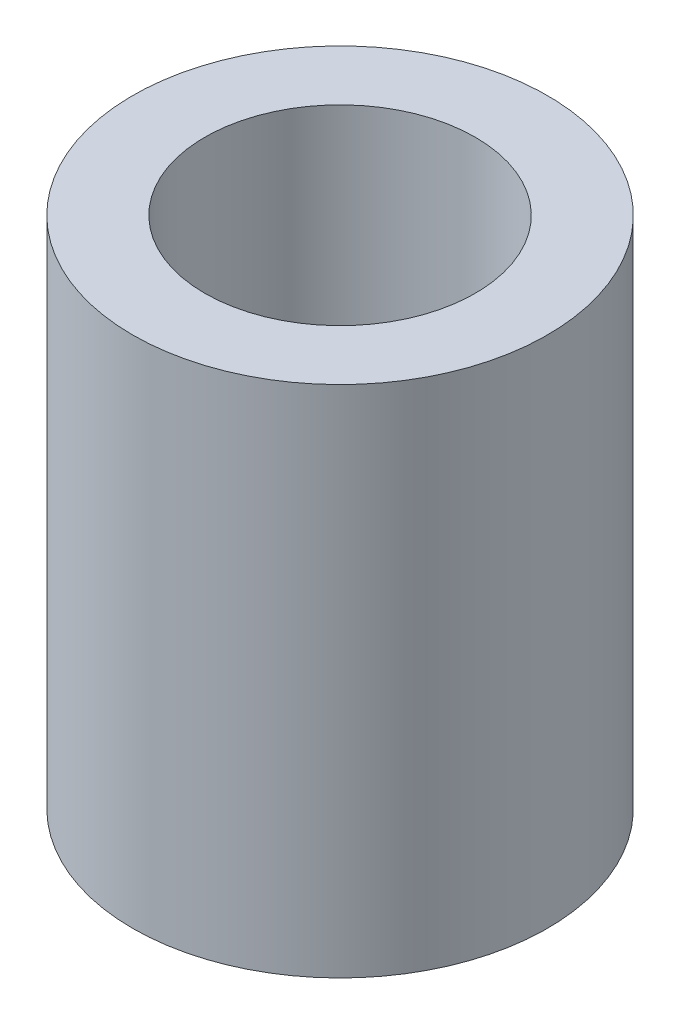
from build123d import *

# Parameters (mm, degrees)
SKETCH1_R           = 2.3
SKETCH1_R_2         = 1.5
BOSS_EXTRUDE1_DEPTH = 2.85


with BuildPart() as part:
    # Sketch1 → Boss-Extrude1 (new body, symmetric)
    with BuildSketch(Plane(origin=(0, 0, 0), x_dir=(1, 0, 0), z_dir=(0, 1, 0))):
        Circle(SKETCH1_R)
        Circle(SKETCH1_R_2, mode=Mode.SUBTRACT)
    extrude(amount=BOSS_EXTRUDE1_DEPTH, both=True)


solid = part.part
